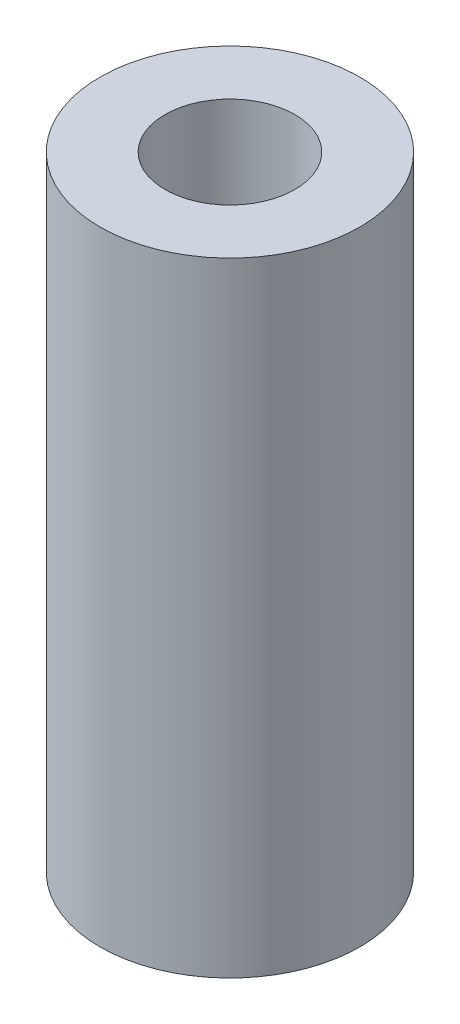
from build123d import *

# Parameters (mm, degrees)
SKETCH1_R                   = 2.5
BOSS_EXTRUDE1_DEPTH         = 12
TAP_DRILL_FOR_M3X0_5_TAP1_D = 2.5


with BuildPart() as part:
    # Sketch1 → Boss-Extrude1 (new body)
    with BuildSketch(Plane(origin=(0, 0, 0), x_dir=(1, 0, 0), z_dir=(0, 1, 0))):
        Circle(SKETCH1_R)
    extrude(amount=BOSS_EXTRUDE1_DEPTH)

    # Tap Drill for M3x0.5 Tap1 (through all)
    with Locations(Plane(origin=(0, 0, 0), x_dir=(-1, 0, 0), z_dir=(0, -1, 0))):
        with Locations((0, 0)):
            Hole(TAP_DRILL_FOR_M3X0_5_TAP1_D / 2)


solid = part.part
